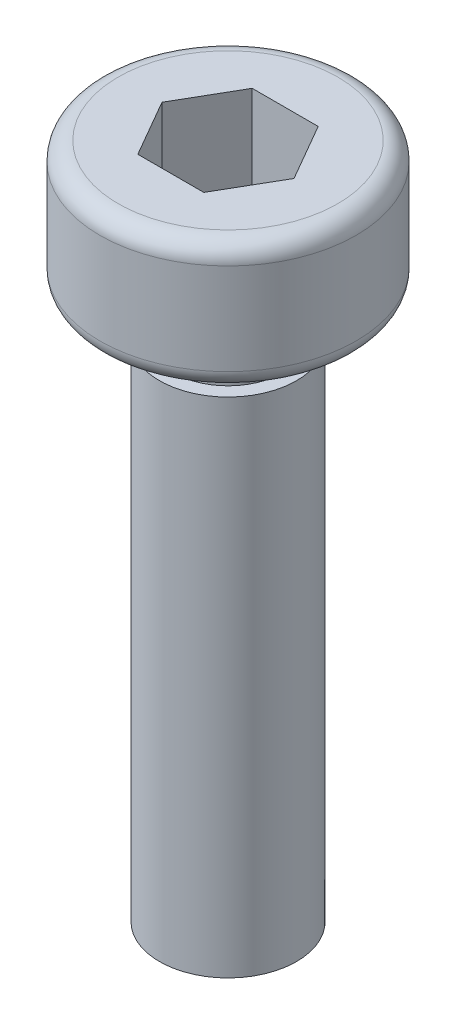
from build123d import *

# Parameters (mm, degrees)
CUT_EXTRUDE_1_DEPTH = 2


with BuildPart() as part:
    # 草图1 → 旋转1 (revolve)
    with BuildSketch(Plane.XY):
        with BuildLine():
            Line((0, 14.8), (-2.4, 14.8))
            ThreePointArc((-2.4, 14.8), (-2.682842712, 14.682842712), (-2.8, 14.4))
            Line((-2.8, 14.4), (-2.8, 12.4))
            ThreePointArc((-2.8, 12.4), (-2.682842712, 12.117157288), (-2.4, 12))
            Line((-2.4, 12), (-1.2, 12))
            Line((-1.2, 12), (-1.2, 11))
            Line((-1.2, 11), (-1.5, 11))
            Line((-1.5, 11), (-1.5, 0))
            Line((-1.5, 0), (0, 0))
            Line((0, 0), (0, 14.8))
        make_face()
    revolve(axis=Axis((0, 0, 0), (0, 1, 0)))

    # 草图2 → 切除-拉伸1 (cut)
    with BuildSketch(Plane(origin=(0, 14.8, 0), x_dir=(1, 0, 0), z_dir=(0, 1, 0))):
        Polygon((-0.721687836, 1.25), (-1.443375673, 0), (-0.721687836, -1.25), (0.721687836, -1.25), (1.443375673, 0), (0.721687836, 1.25), align=None)
    extrude(amount=-CUT_EXTRUDE_1_DEPTH, mode=Mode.SUBTRACT)


solid = part.part
